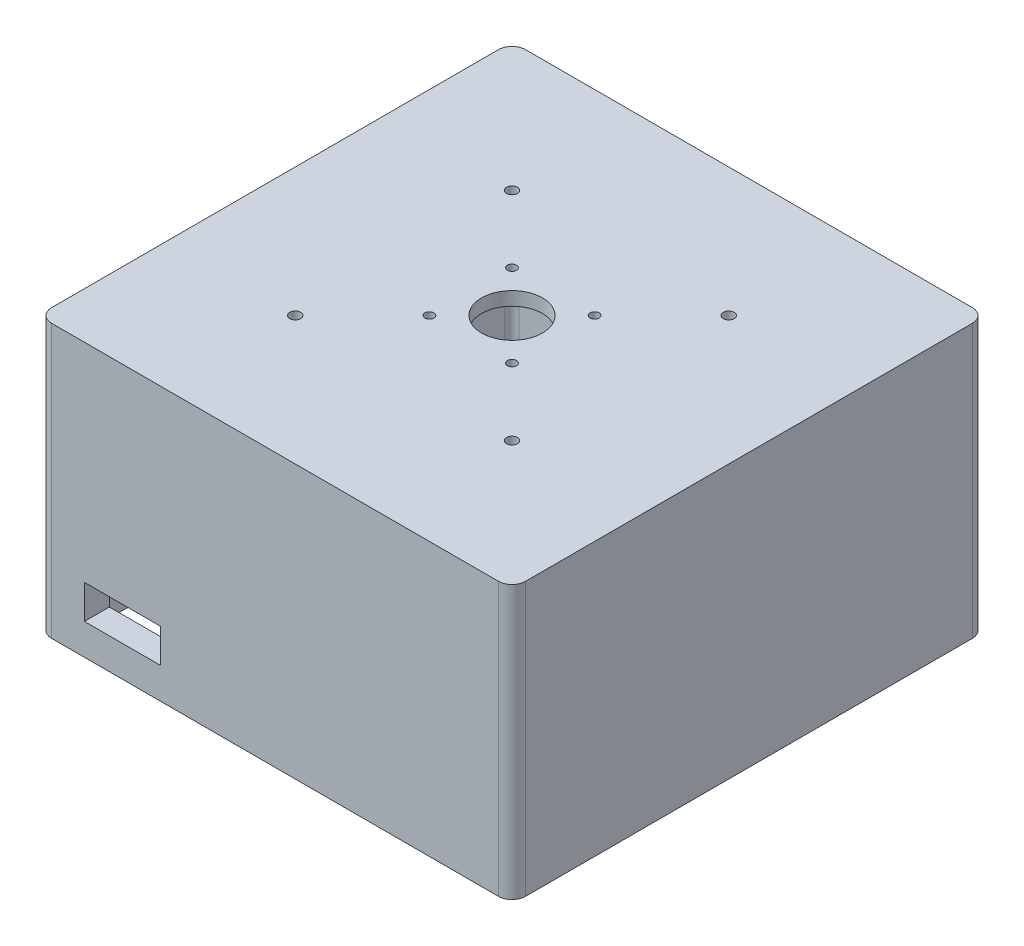
from build123d import *

# Parameters (mm, degrees)
SKETCH1_W                = 177.8
SKETCH1_H                = 177.8
SKETCH1_W_2              = 159.078855478
SKETCH1_H_2              = 159.078855478
BOSS_EXTRUDE1_DEPTH      = 38.1
BOSS_EXTRUDE1_DEPTH_BACK = 59.182
BOSS_EXTRUDE3_START      = 38.1
SKETCH1_5_W              = 177.8
SKETCH1_5_H              = 177.8
SKETCH1_5_W_2            = 159.078855478
SKETCH1_5_H_2            = 159.078855478
SKETCH1_5_R              = 11.43
BOSS_EXTRUDE3_DEPTH      = 5.08
FILLET1_R                = 5.08
SKETCH3_R                = 1.7
CUT_EXTRUDE1_DEPTH       = 103.362
FILLET2_R                = 2.54
SKETCH4_R                = 2.05
CUT_EXTRUDE2_DEPTH       = 5.08
SKETCH5_W                = 28.575
SKETCH5_H                = 12.7
CUT_EXTRUDE3_DEPTH       = 9.360572


with BuildPart() as part:
    # Sketch1 → Boss-Extrude1 (new body, two sides)
    with BuildSketch(Plane(origin=(0, 0, 0), x_dir=(1, 0, 0), z_dir=(0, 1, 0))) as boss_extrude1_sk:
        Rectangle(SKETCH1_W, SKETCH1_H)
        Rectangle(SKETCH1_W_2, SKETCH1_H_2, mode=Mode.SUBTRACT)
    extrude(amount=BOSS_EXTRUDE1_DEPTH)
    extrude(boss_extrude1_sk.sketch, amount=-BOSS_EXTRUDE1_DEPTH_BACK)

    # Sketch1_5 → Boss-Extrude3 (add)
    with BuildSketch(Plane(origin=(0, 0, 0), x_dir=(1, 0, 0), z_dir=(0, 1, 0)).offset(BOSS_EXTRUDE3_START)):
        Rectangle(SKETCH1_5_W, SKETCH1_5_H)
        Rectangle(SKETCH1_5_W_2, SKETCH1_5_H_2, mode=Mode.SUBTRACT)
        Rectangle(SKETCH1_5_W_2, SKETCH1_5_H_2)
        Circle(SKETCH1_5_R, mode=Mode.SUBTRACT)
    extrude(amount=BOSS_EXTRUDE3_DEPTH)

    # Fillet1
    fillet1_edges = [part.edges().sort_by_distance(p)[0] for p in [
        (-88.9, -8.001, 88.9),
        (-88.9, -8.001, -88.9),
        (88.9, -8.001, -88.9),
        (88.9, -8.001, 88.9),
    ]]
    fillet(fillet1_edges, radius=FILLET1_R)

    # Sketch3 → Cut-Extrude1 (cut, through all)
    with BuildSketch(Plane(origin=(0, 43.18, 0), x_dir=(1, 0, 0), z_dir=(0, 1, 0))):
        with Locations((-15.5, 15.5)):
            Circle(SKETCH3_R)
        with Locations((-15.5, -15.5)):
            Circle(SKETCH3_R)
        with Locations((15.5, 15.5)):
            Circle(SKETCH3_R)
        with Locations((15.5, -15.5)):
            Circle(SKETCH3_R)
    extrude(amount=-CUT_EXTRUDE1_DEPTH, mode=Mode.SUBTRACT)

    # Fillet2
    fillet2_edges = [part.edges().sort_by_distance(p)[0] for p in [
        (79.539427739, -10.541, -79.539427739),
        (-79.539427739, -10.541, -79.539427739),
        (-79.539427739, -10.541, 79.539427739),
        (79.539427739, -10.541, 79.539427739),
    ]]
    fillet(fillet2_edges, radius=FILLET2_R)

    # Sketch4 → Cut-Extrude2 (cut)
    with BuildSketch(Plane(origin=(0, 43.18, 0), x_dir=(1, 0, 0), z_dir=(0, 1, 0))):
        with Locations((-40.66, 40.66)):
            Circle(SKETCH4_R)
        with Locations((40.66, 40.66)):
            Circle(SKETCH4_R)
        with Locations((-40.66, -40.66)):
            Circle(SKETCH4_R)
        with Locations((40.66, -40.66)):
            Circle(SKETCH4_R)
    extrude(amount=-CUT_EXTRUDE2_DEPTH, mode=Mode.SUBTRACT)

    # Sketch5 → Cut-Extrude3 (cut)
    with BuildSketch(Plane.XY.offset(88.9)):
        with Locations((-57.223240987, -41.174341157)):
            Rectangle(SKETCH5_W, SKETCH5_H)
    extrude(amount=-CUT_EXTRUDE3_DEPTH, mode=Mode.SUBTRACT)


solid = part.part
